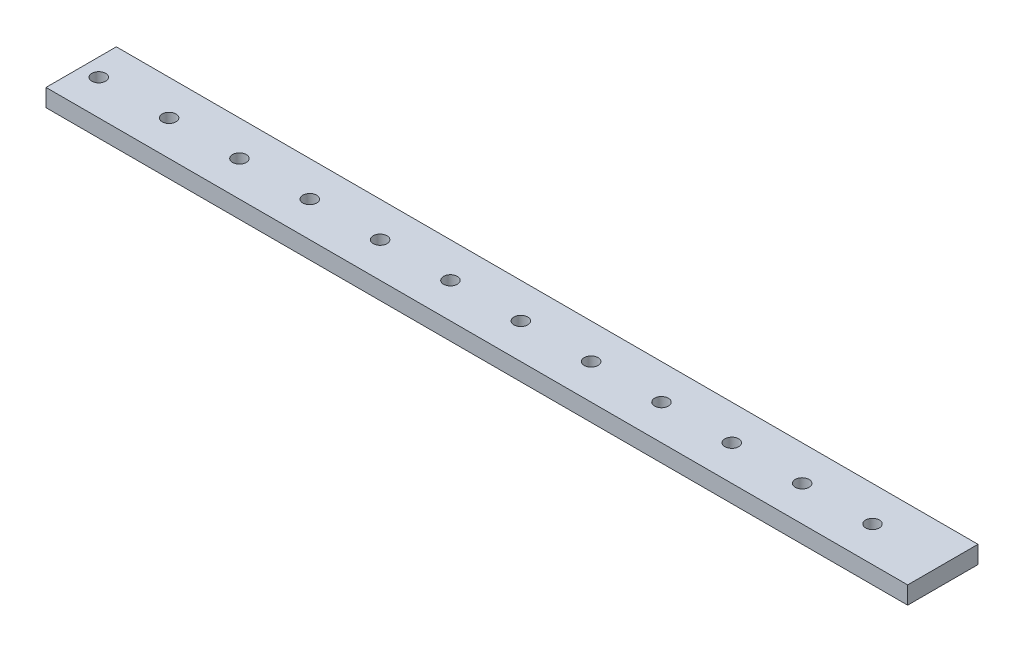
from build123d import *

# Parameters (mm, degrees)
SKETCH1_W               = 406.4
SKETCH1_H               = 25.4
BOSS_EXTRUDE1_DEPTH     = 6.35
SKETCH2_R               = 2.4892
CUT_EXTRUDE1_DEPTH      = 1
CUT_EXTRUDE1_DEPTH_BACK = 7.35
SKETCH3_R               = 2.378070279
SKETCH3_R_2             = 2.20737703
CUT_EXTRUDE2_DEPTH      = 7.35
SKETCH4_W               = 25.4
SKETCH4_H               = 6.35
CUT_EXTRUDE3_DEPTH      = 95.25


with BuildPart() as part:
    # Sketch1 → Boss-Extrude1 (new body)
    with BuildSketch(Plane(origin=(0, 0, 0), x_dir=(1, 0, 0), z_dir=(0, 1, 0))):
        with Locations((203.2, 12.7)):
            Rectangle(SKETCH1_W, SKETCH1_H)
    extrude(amount=BOSS_EXTRUDE1_DEPTH)

    # Sketch2 → Cut-Extrude1 (cut, two sides)
    with BuildSketch(Plane(origin=(0, 6.35, 0), x_dir=(1, 0, 0), z_dir=(0, 1, 0))) as cut_extrude1_sk:
        with Locations((381, 12.7)):
            Circle(SKETCH2_R)
        with Locations((355.6, 12.7)):
            Circle(SKETCH2_R)
        with Locations((330.2, 12.7)):
            Circle(SKETCH2_R)
        with Locations((304.8, 12.7)):
            Circle(SKETCH2_R)
        with Locations((279.4, 12.7)):
            Circle(SKETCH2_R)
        with Locations((254, 12.7)):
            Circle(SKETCH2_R)
        with Locations((228.6, 12.7)):
            Circle(SKETCH2_R)
        with Locations((203.2, 12.7)):
            Circle(SKETCH2_R)
        with Locations((177.8, 12.7)):
            Circle(SKETCH2_R)
        with Locations((152.4, 12.7)):
            Circle(SKETCH2_R)
        with Locations((127, 12.7)):
            Circle(SKETCH2_R)
        with Locations((101.6, 12.7)):
            Circle(SKETCH2_R)
    extrude(amount=CUT_EXTRUDE1_DEPTH, mode=Mode.SUBTRACT)
    extrude(cut_extrude1_sk.sketch, amount=-CUT_EXTRUDE1_DEPTH_BACK, mode=Mode.SUBTRACT)

    # Sketch3 → Cut-Extrude2 (cut, through all)
    with BuildSketch(Plane.XZ):
        with Locations((63.5, -12.7)):
            Circle(SKETCH3_R)
        with Locations((38.1, -12.7)):
            Circle(SKETCH3_R_2)
    extrude(amount=-CUT_EXTRUDE2_DEPTH, mode=Mode.SUBTRACT)

    # Sketch4 → Cut-Extrude3 (cut)
    with BuildSketch(Plane.ZY):
        with Locations((-12.7, 3.175)):
            Rectangle(SKETCH4_W, SKETCH4_H)
    extrude(amount=-CUT_EXTRUDE3_DEPTH, mode=Mode.SUBTRACT)


solid = part.part
